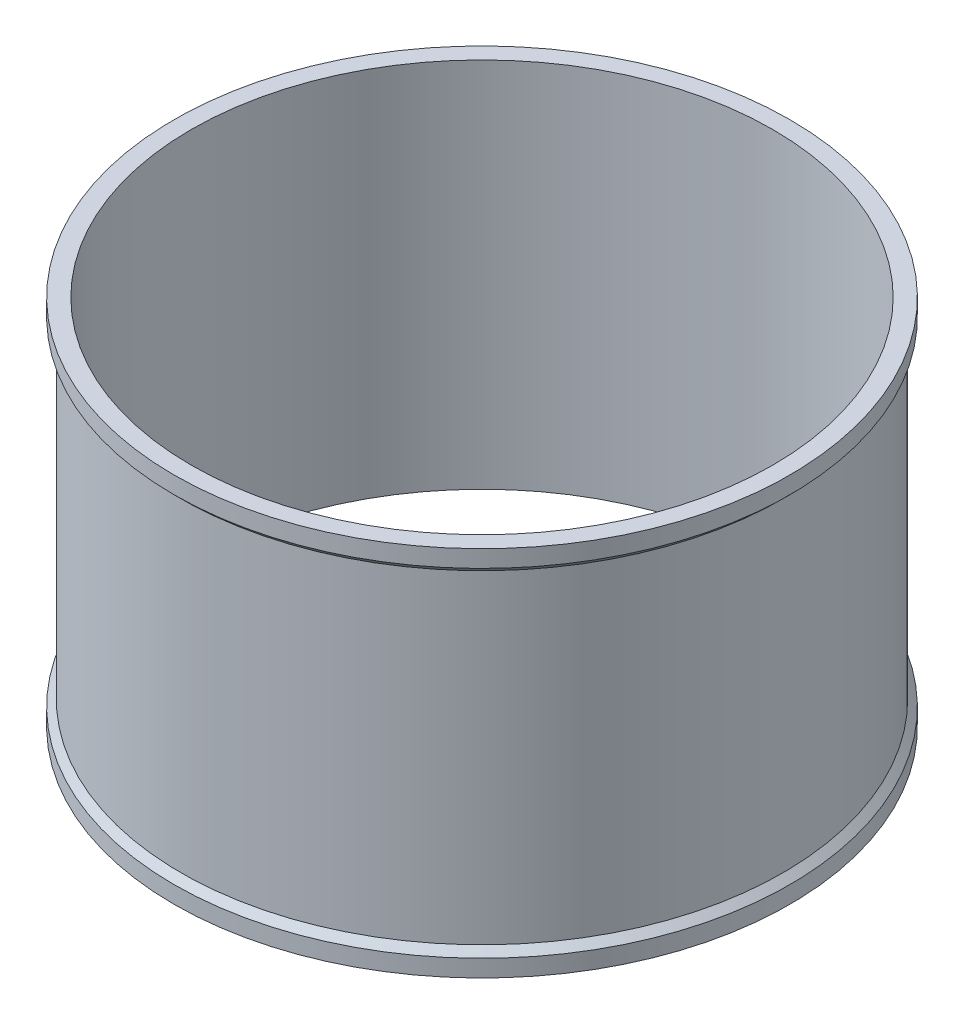
from build123d import *


with BuildPart() as part:
    # Sketch1 → Revolve1 (revolve)
    with BuildSketch(Plane.XY):
        Polygon((85, 0), (90, 0), (90, 5), (88, 7), (88, 101.7), (90, 103.7), (90, 108.7), (85, 108.7), align=None)
    revolve(axis=Axis((0, 0, 0), (0, 1, 0)))


solid = part.part
